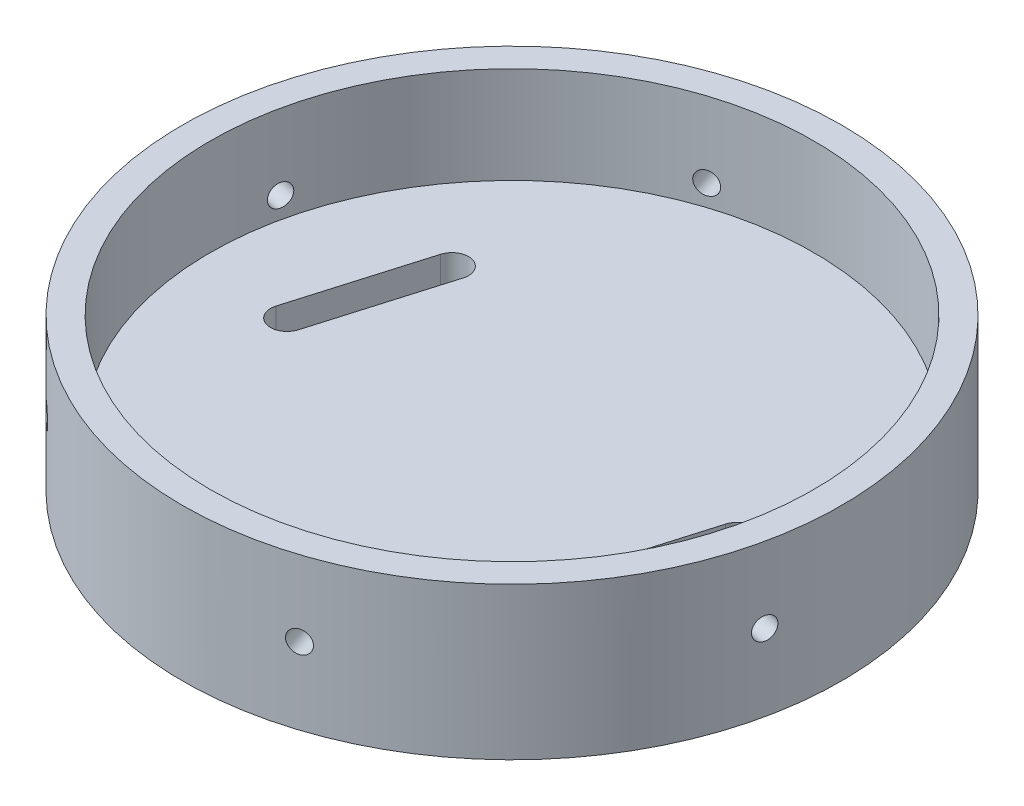
from build123d import *

# Parameters (mm, degrees)
SKETCH1_R                            = 75.692
SKETCH1_R_2                          = 69.342
BOSS_EXTRUDE1_DEPTH                  = 22.225
SKETCH2_R                            = 75.692
BOSS_EXTRUDE2_DEPTH                  = 12.7
TAP_DRILL_FOR_1_4_20_TAP1_AT_2_COUNT = 2
TAP_DRILL_FOR_1_4_20_TAP1_AT_2_PITCH = 53.488399339
CIRPATTERN1_COUNT                    = 6
F_1_2_0_5_DIAMETER_HOLE1_D           = 12.7
CUT_EXTRUDE1_DEPTH                   = 13.7000001


with BuildPart() as part:
    # Sketch1 → Boss-Extrude1 (new body)
    with BuildSketch(Plane(origin=(0, 0, 0), x_dir=(1, 0, 0), z_dir=(0, 1, 0))):
        Circle(SKETCH1_R)
        Circle(SKETCH1_R_2, mode=Mode.SUBTRACT)
    extrude(amount=BOSS_EXTRUDE1_DEPTH)

    # Sketch2 → Boss-Extrude2 (add)
    with BuildSketch(Plane.XZ):
        Circle(SKETCH2_R)
    extrude(amount=BOSS_EXTRUDE2_DEPTH)

    # Sketch4 → Tap Drill for 1/4-20 Tap1 (revolve, cut)
    with BuildSketch(Plane(origin=(73.997176623, 4.896298223, 15.927859738), x_dir=(0.210429897, 0, -0.97760895), z_dir=(0, 1, 0))):
        Polygon((0, 0), (0, 11.185816902), (2.5527, 9.652), (2.5527, 0), align=None)
    tap_drill_for_1_4_20_tap1 = revolve(axis=Axis((80.204993454, 4.896298223, 17.264089582), (-0.97760895, 0, -0.210429897)), mode=Mode.SUBTRACT)

    # Tap Drill for 1/4-20 Tap1 at 2: Tap Drill for 1/4-20 Tap1 ×2
    with Locations(*[Vector(-0.110438581, 0.851210999, 0.51307227) * (i * TAP_DRILL_FOR_1_4_20_TAP1_AT_2_PITCH) for i in range(1, TAP_DRILL_FOR_1_4_20_TAP1_AT_2_COUNT)]):
        add(tap_drill_for_1_4_20_tap1, mode=Mode.SUBTRACT)

    # CirPattern1: Tap Drill for 1/4-20 Tap1 ×6 about axis
    cirpattern1_axis = Axis((0, 22.225, 0), (0, -1, 0))
    for i in range(1, CIRPATTERN1_COUNT):
        add(tap_drill_for_1_4_20_tap1.rotate(cirpattern1_axis, i * 360 / CIRPATTERN1_COUNT), mode=Mode.SUBTRACT)

    # CirPattern1 copy 1 sketch → CirPattern1 copy 1 (revolve, cut)
    with BuildSketch(Plane(origin=(-3.515628412, 50.426212075, 80.653301416), x_dir=(0.951849134, 0, -0.306566839), z_dir=(0, 1, 0))):
        Polygon((0, 0), (0, 11.185816902), (2.5527, 9.652), (2.5527, 0), align=None)
    revolve(axis=Axis((-1.568928987, 50.426212075, 86.697543415), (-0.306566839, 0, -0.951849134)), mode=Mode.SUBTRACT)

    # CirPattern1 copy 2 sketch → CirPattern1 copy 2 (revolve, cut)
    with BuildSketch(Plane(origin=(-71.605622131, 50.426212075, 37.282027193), x_dir=(0.741419237, 0, 0.671042111), z_dir=(0, 1, 0))):
        Polygon((0, 0), (0, 11.185816902), (2.5527, 9.652), (2.5527, 0), align=None)
    revolve(axis=Axis((-75.866739537, 50.426212075, 41.990039348), (0.671042111, 0, -0.741419237)), mode=Mode.SUBTRACT)

    # CirPattern1 copy 3 sketch → CirPattern1 copy 3 (revolve, cut)
    with BuildSketch(Plane(origin=(-68.089993719, 50.426212075, -43.371274223), x_dir=(-0.210429897, 0, 0.97760895), z_dir=(0, 1, 0))):
        Polygon((0, 0), (0, 11.185816902), (2.5527, 9.652), (2.5527, 0), align=None)
    revolve(axis=Axis((-74.29781055, 50.426212075, -44.707504067), (0.97760895, 0, 0.210429897)), mode=Mode.SUBTRACT)

    # CirPattern1 copy 4 sketch → CirPattern1 copy 4 (revolve, cut)
    with BuildSketch(Plane(origin=(3.515628412, 50.426212075, -80.653301416), x_dir=(-0.951849134, 0, 0.306566839), z_dir=(0, 1, 0))):
        Polygon((0, 0), (0, 11.185816902), (2.5527, 9.652), (2.5527, 0), align=None)
    revolve(axis=Axis((1.568928987, 50.426212075, -86.697543415), (0.306566839, 0, 0.951849134)), mode=Mode.SUBTRACT)

    # CirPattern1 copy 5 sketch → CirPattern1 copy 5 (revolve, cut)
    with BuildSketch(Plane(origin=(71.605622131, 50.426212075, -37.282027193), x_dir=(-0.741419237, 0, -0.671042111), z_dir=(0, 1, 0))):
        Polygon((0, 0), (0, 11.185816902), (2.5527, 9.652), (2.5527, 0), align=None)
    revolve(axis=Axis((75.866739537, 50.426212075, -41.990039348), (-0.671042111, 0, 0.741419237)), mode=Mode.SUBTRACT)

    # 1/2 (0.5) Diameter Hole1 (through all)
    with Locations(Plane(origin=(0, 0, 0), x_dir=(1, 0, 0), z_dir=(0, 1, 0))):
        with Locations((0, -50.8)):
            Hole(F_1_2_0_5_DIAMETER_HOLE1_D / 2)

    # Sketch11 → Cut-Extrude1 (cut, through all)
    with BuildSketch(Plane(origin=(0, 0, 0), x_dir=(1, 0, 0), z_dir=(0, 1, 0))):
        with BuildLine():
            Line((-51.165057741, -3.071167846), (-42.54303006, 26.163931584))
            ThreePointArc((-42.54303006, 26.163931584), (-37.810889171, 28.740565552), (-35.234255202, 24.008424663))
            Line((-35.234255202, 24.008424663), (-43.856282883, -5.226674766))
            ThreePointArc((-43.856282883, -5.226674766), (-48.588423772, -7.803308735), (-51.165057741, -3.071167846))
        make_face()
        with BuildLine():
            Line((35.234255202, -24.008424663), (43.856282883, 5.226674766))
            ThreePointArc((43.856282883, 5.226674766), (48.588423772, 7.803308735), (51.165057741, 3.071167846))
            Line((51.165057741, 3.071167846), (42.54303006, -26.163931584))
            ThreePointArc((42.54303006, -26.163931584), (37.810889171, -28.740565552), (35.234255202, -24.008424663))
        make_face()
    extrude(amount=-CUT_EXTRUDE1_DEPTH, mode=Mode.SUBTRACT)


solid = part.part
